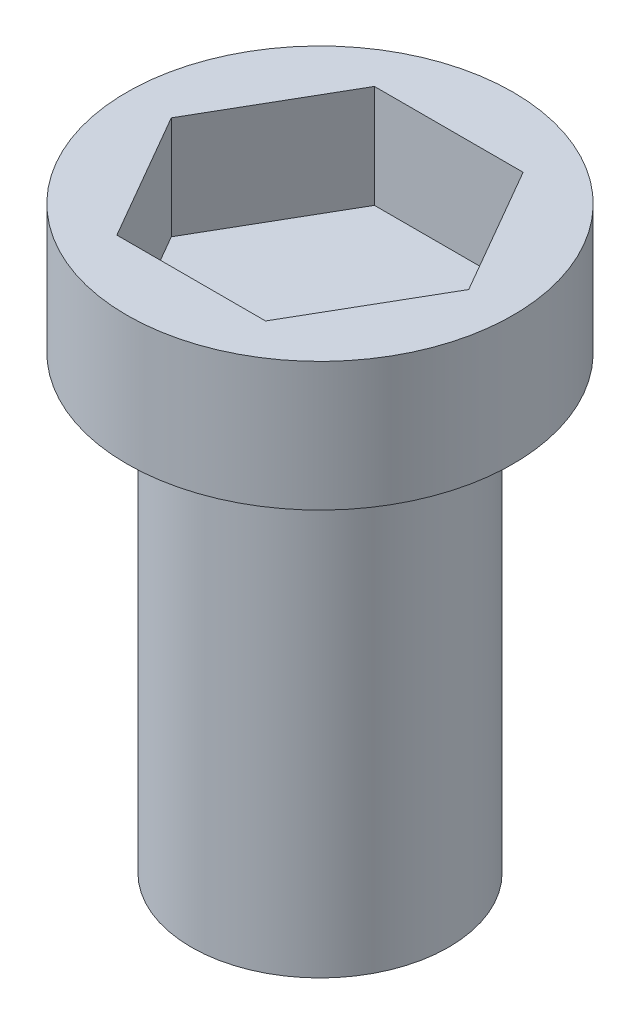
from build123d import *

# Parameters (mm, degrees)
SKETCH2_R           = 15
BOSS_EXTRUDE1_DEPTH = 10
SKETCH4_R           = 15
BOSS_EXTRUDE2_DEPTH = 2
SKETCH5_R           = 10
BOSS_EXTRUDE3_DEPTH = 35


with BuildPart() as part:
    # Sketch2 → Boss-Extrude1 (new body)
    with BuildSketch(Plane(origin=(0, 0, 0), x_dir=(1, 0, 0), z_dir=(0, 1, 0))):
        Circle(SKETCH2_R)
        Polygon((5.773502692, 10), (-5.773502692, 10), (-11.547005384, 0), (-5.773502692, -10), (5.773502692, -10), (11.547005384, 0), align=None, mode=Mode.SUBTRACT)
    extrude(amount=BOSS_EXTRUDE1_DEPTH)

    # Sketch4 → Boss-Extrude2 (add)
    with BuildSketch(Plane.XZ):
        Circle(SKETCH4_R)
    extrude(amount=-BOSS_EXTRUDE2_DEPTH)

    # Sketch5 → Boss-Extrude3 (add)
    with BuildSketch(Plane.XZ):
        Circle(SKETCH5_R)
    extrude(amount=BOSS_EXTRUDE3_DEPTH)


solid = part.part
